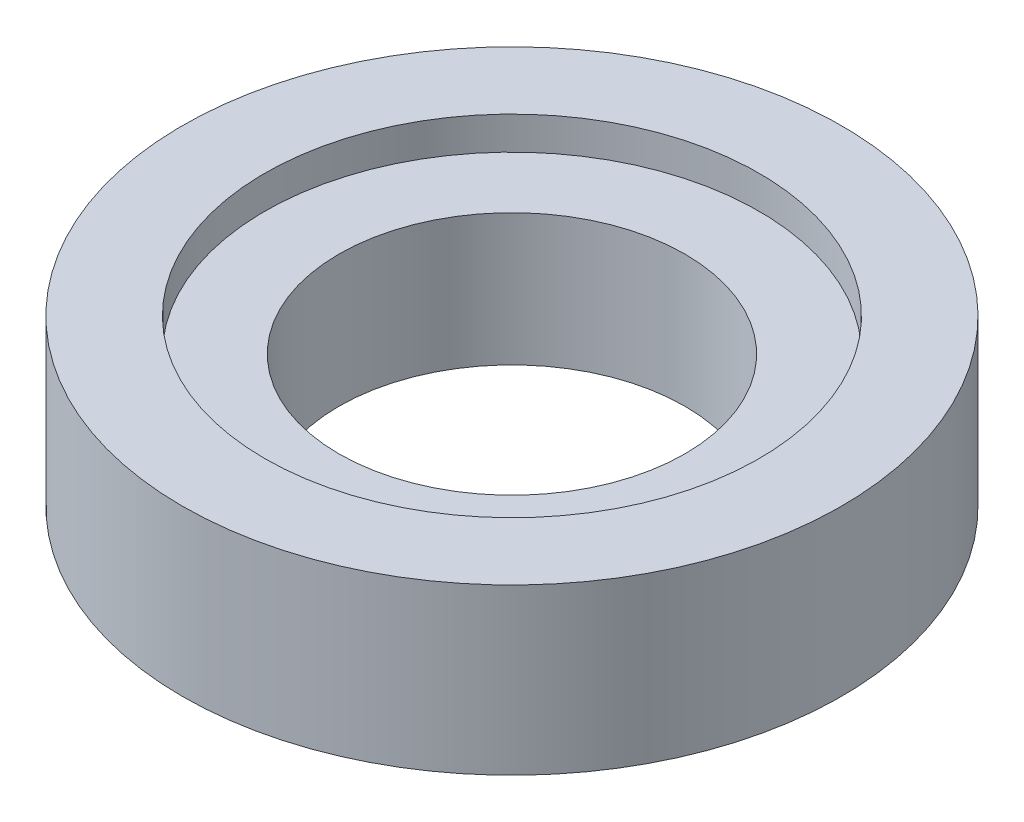
from build123d import *

# Parameters (mm, degrees)
ESQUISSE1_R             = 10
ESQUISSE1_R_2           = 5.25
BOSS_EXTRU_1_DEPTH      = 5
ESQUISSE2_R             = 7.5
ENL_V_MAT_EXTRU_1_DEPTH = 1


with BuildPart() as part:
    # Esquisse1 → Boss.-Extru.1 (new body)
    with BuildSketch(Plane(origin=(0, 0, 0), x_dir=(1, 0, 0), z_dir=(0, 1, 0))):
        Circle(ESQUISSE1_R)
        Circle(ESQUISSE1_R_2, mode=Mode.SUBTRACT)
    extrude(amount=BOSS_EXTRU_1_DEPTH)

    # Esquisse2 → Enlèv. mat.-Extru.1 (cut)
    with BuildSketch(Plane(origin=(0, 5, 0), x_dir=(1, 0, 0), z_dir=(0, 1, 0))):
        Circle(ESQUISSE2_R)
    extrude(amount=-ENL_V_MAT_EXTRU_1_DEPTH, mode=Mode.SUBTRACT)


solid = part.part
